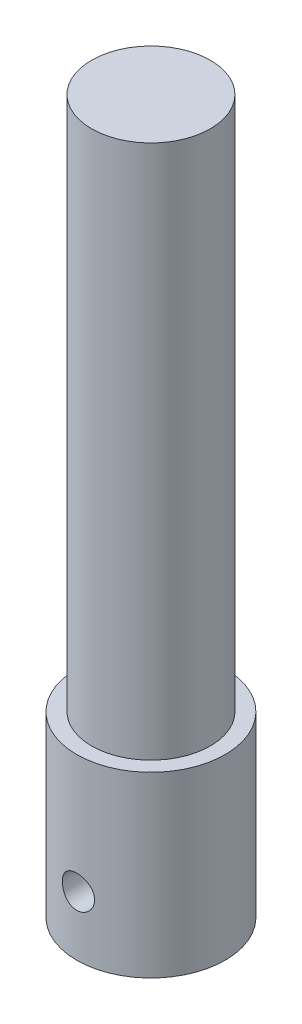
from build123d import *

# Parameters (mm, degrees)
SKETCH1_R                      = 7.9375
BOSS_EXTRUDE1_DEPTH            = 76.2
M6X1_0_TAPPED_HOLE1_D          = 5
M6X1_0_TAPPED_HOLE1_DEPTH      = 29.9999908
M6X1_0_TAPPED_HOLE1_TIP        = 1.502151548
F_10_0_10_DIAMETER_HOLE2_D     = 10
F_10_0_10_DIAMETER_HOLE2_DEPTH = 13.9999974
F_10_0_10_DIAMETER_HOLE2_TIP   = 3.004303095
F_8_32_TAPPED_HOLE1_D          = 3.4544
SKETCH15_R                     = 7.9375
SKETCH15_R_2                   = 6.35
CUT_EXTRUDE2_DEPTH             = 57.15


with BuildPart() as part:
    # Sketch1 → Boss-Extrude1 (new body)
    with BuildSketch(Plane(origin=(0, 0, 0), x_dir=(1, 0, 0), z_dir=(0, 1, 0))):
        Circle(SKETCH1_R)
    extrude(amount=BOSS_EXTRUDE1_DEPTH)

    # M6x1.0 Tapped Hole1
    with Locations(Plane(origin=(0, 0, 0), x_dir=(-1, 0, 0), z_dir=(0, -1, 0))):
        with Locations((0, 0)):
            Hole(M6X1_0_TAPPED_HOLE1_D / 2, depth=M6X1_0_TAPPED_HOLE1_DEPTH)
            with Locations((0, 0, -(M6X1_0_TAPPED_HOLE1_DEPTH + M6X1_0_TAPPED_HOLE1_TIP / 2))):  # 118° drill point
                Cone(0, M6X1_0_TAPPED_HOLE1_D / 2, M6X1_0_TAPPED_HOLE1_TIP, mode=Mode.SUBTRACT)

    # Ø10.0 (10) Diameter Hole2
    with Locations(Plane(origin=(0, 0, 0), x_dir=(-1, 0, 0), z_dir=(0, -1, 0))):
        with Locations((0, 0)):
            Hole(F_10_0_10_DIAMETER_HOLE2_D / 2, depth=F_10_0_10_DIAMETER_HOLE2_DEPTH)
            with Locations((0, 0, -(F_10_0_10_DIAMETER_HOLE2_DEPTH + F_10_0_10_DIAMETER_HOLE2_TIP / 2))):  # 118° drill point
                Cone(0, F_10_0_10_DIAMETER_HOLE2_D / 2, F_10_0_10_DIAMETER_HOLE2_TIP, mode=Mode.SUBTRACT)

    # #8-32 Tapped Hole1 (through all)
    with Locations(Plane.XY.offset(7.9375)):
        with Locations((0, 6.35)):
            Hole(F_8_32_TAPPED_HOLE1_D / 2)

    # Sketch15 → Cut-Extrude2 (cut)
    with BuildSketch(Plane(origin=(0, 76.2, 0), x_dir=(1, 0, 0), z_dir=(0, 1, 0))):
        Circle(SKETCH15_R)
        Circle(SKETCH15_R_2, mode=Mode.SUBTRACT)
    extrude(amount=-CUT_EXTRUDE2_DEPTH, mode=Mode.SUBTRACT)


solid = part.part
